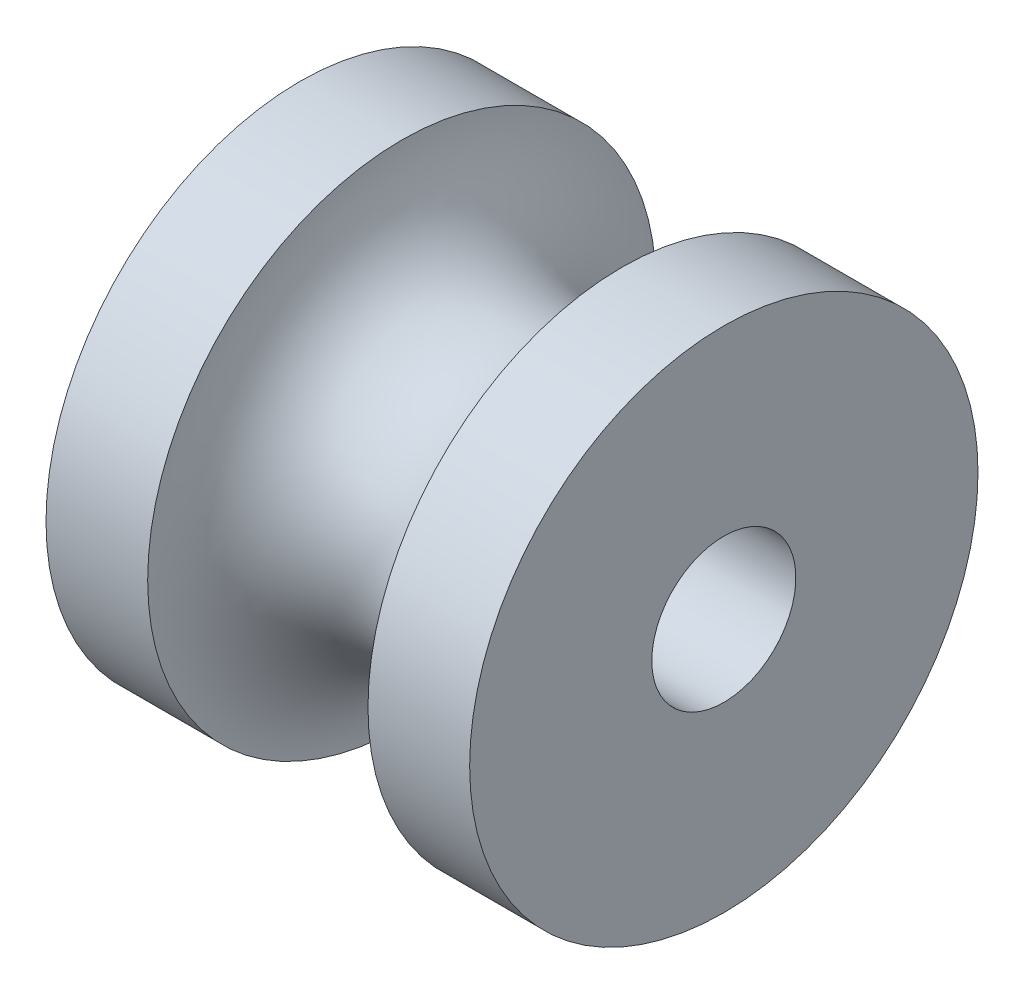
from build123d import *


with BuildPart() as part:
    # Esquisse2 → Révolution1 (revolve)
    with BuildSketch(Plane.XY):
        with BuildLine():
            Line((-5, -6), (-2.6, -6))
            ThreePointArc((-2.6, -6), (0, -3.4), (2.6, -6))
            Line((2.6, -6), (5, -6))
            Line((5, -6), (5, -1.7))
            Line((5, -1.7), (-5, -1.7))
            Line((-5, -1.7), (-5, -6))
        make_face()
    revolve(axis=Axis((-9.599452589, 0, 0), (1, 0, 0)))


solid = part.part
